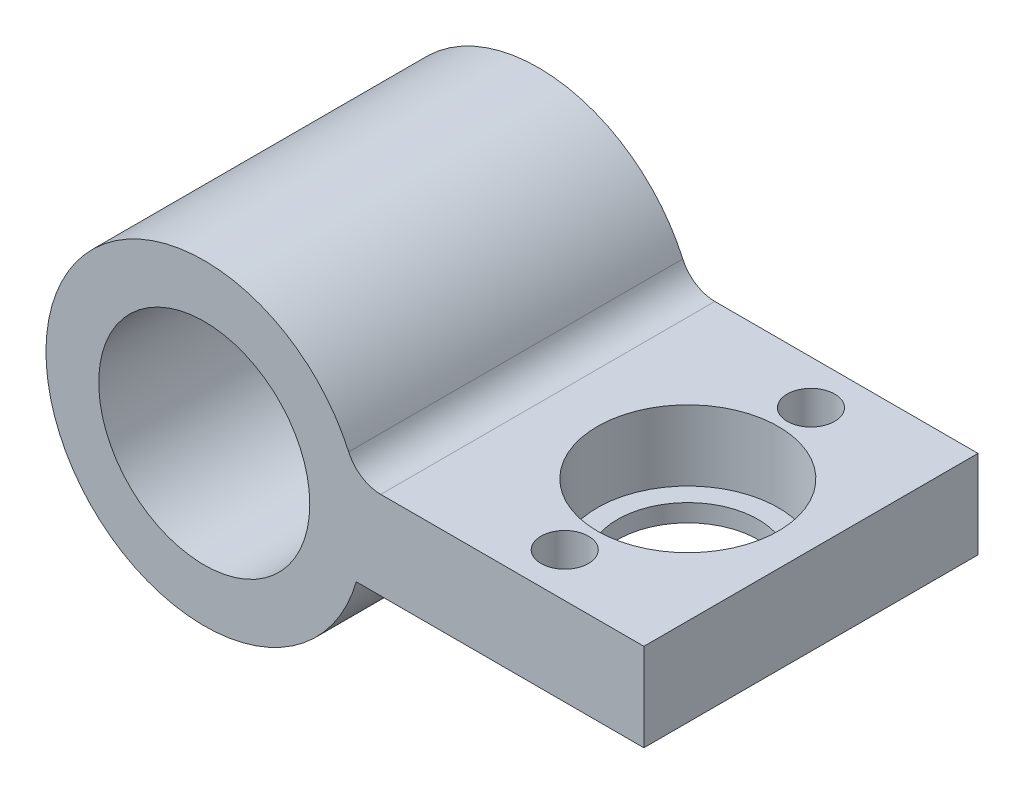
from build123d import *

# Parameters (mm, degrees)
SKETCH1_R                  = 9
SKETCH1_R_2                = 6
MAIN_DEPTH                 = 9.5
SKETCH2_W                  = 25
SKETCH2_H                  = 19
SKETCH2_R                  = 4
SKETCH2_R_2                = 1.35
BALLSUPPORTEXTRUSION_DEPTH = 2.5
SKETCH3_R                  = 5.15
BALLSUPPORTHOLE_DEPTH      = 4
FILLET2_R                  = 2
SKETCH5_R                  = 6
CUT_EXTRUDE2_DEPTH         = 20


with BuildPart() as part:
    # Sketch1 → Main (new body, symmetric)
    with BuildSketch(Plane.XY):
        Circle(SKETCH1_R)
        Circle(SKETCH1_R_2, mode=Mode.SUBTRACT)
    extrude(amount=MAIN_DEPTH, both=True)

    # Sketch2 → BallSupportExtrusion (add, symmetric)
    with BuildSketch(Plane(origin=(0, 0, 0), x_dir=(1, 0, 0), z_dir=(0, 1, 0))):
        with Locations((12.5, 0)):
            Rectangle(SKETCH2_W, SKETCH2_H)
        with Locations((18, 0)):
            Circle(SKETCH2_R, mode=Mode.SUBTRACT)
        with Locations((18, 7)):
            Circle(SKETCH2_R_2, mode=Mode.SUBTRACT)
        with Locations((18, -7)):
            Circle(SKETCH2_R_2, mode=Mode.SUBTRACT)
    extrude(amount=BALLSUPPORTEXTRUSION_DEPTH, both=True)

    # Sketch3 → BallSupportHole (cut)
    with BuildSketch(Plane(origin=(0, 2.5, 0), x_dir=(1, 0, 0), z_dir=(0, 1, 0))):
        with Locations((18, 0)):
            Circle(SKETCH3_R)
    extrude(amount=-BALLSUPPORTHOLE_DEPTH, mode=Mode.SUBTRACT)

    # Fillet2
    fillet2_edges = [part.edges().sort_by_distance(p)[0] for p in [
        (8.645808233, 2.5, 0),
    ]]
    fillet(fillet2_edges, radius=FILLET2_R)

    # Sketch5 → Cut-Extrude2 (cut, through all)
    with BuildSketch(Plane.XY.offset(9.5)):
        Circle(SKETCH5_R)
    extrude(amount=-CUT_EXTRUDE2_DEPTH, mode=Mode.SUBTRACT)


solid = part.part
